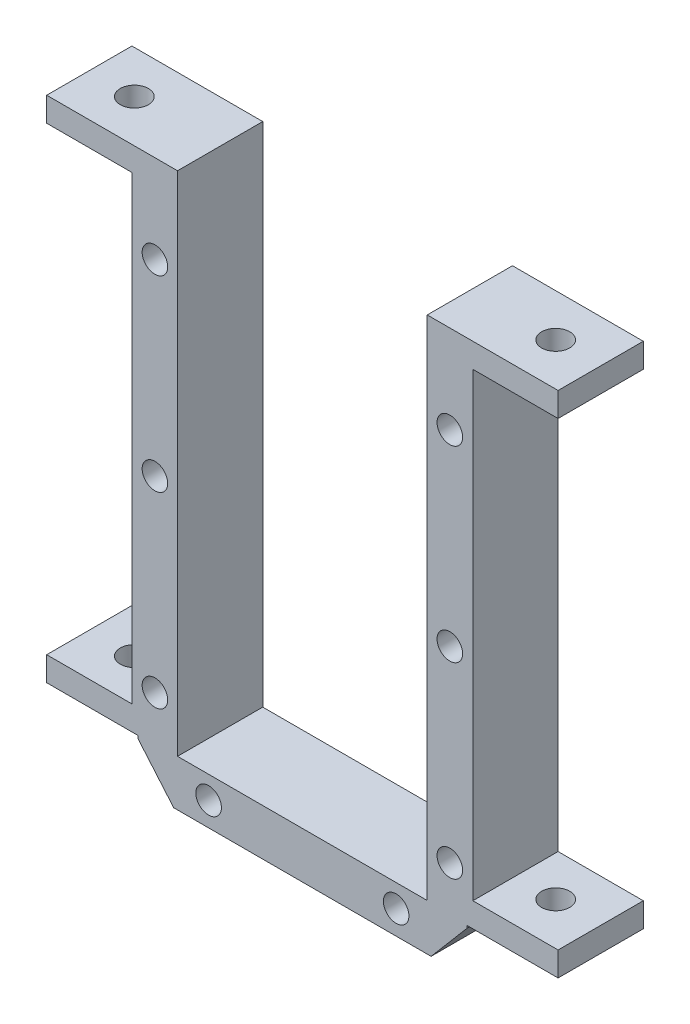
from build123d import *

# Parameters (mm, degrees)
SKETCH1_W               = 40
SKETCH1_H               = 65.1
BOSS_EXTRUDE1_DEPTH     = 10
CUT_EXTRUDE1_DEPTH      = 10
SKETCH4_W               = 29.3
SKETCH4_H               = 59.5
CUT_EXTRUDE2_DEPTH      = 10
SKETCH5_R               = 1.5
CUT_EXTRUDE3_DEPTH      = 10
SKETCH7_W               = 10
SKETCH7_H               = 3
BOSS_EXTRUDE2_DEPTH     = 10
SKETCH8_W               = 10
SKETCH8_H               = 3
BOSS_EXTRUDE3_DEPTH     = 10
SKETCH9_R               = 1.65
CUT_EXTRUDE4_DEPTH      = 61
SKETCH10_R              = 1.65
CUT_EXTRUDE5_DEPTH      = 61
ESQUISSE1_W             = 15.35
ESQUISSE1_H             = 0.15
ESQUISSE1_W_2           = 29.3
ENL_V_MAT_EXTRU_1_DEPTH = 11


with BuildPart() as part:
    # Sketch1 → Boss-Extrude1 (new body)
    with BuildSketch(Plane.XY):
        with Locations((-0.1, 0)):
            Rectangle(SKETCH1_W, SKETCH1_H)
    extrude(amount=BOSS_EXTRUDE1_DEPTH)

    # Sketch2 → Cut-Extrude1 (cut)
    with BuildSketch(Plane.XY.offset(10)):
        Polygon((15, -32.55), (19.335, -27.45), (19.9, -27.45), (19.9, -32.55), align=None)
        Polygon((-20.1, -27.45), (-20.1, -32.55), (-15.2, -32.55), (-19.535, -27.45), align=None)
    extrude(amount=-CUT_EXTRUDE1_DEPTH, mode=Mode.SUBTRACT)

    # Sketch4 → Cut-Extrude2 (cut)
    with BuildSketch(Plane.XY.offset(10)):
        with Locations((-0.1, 2.8)):
            Rectangle(SKETCH4_W, SKETCH4_H)
    extrude(amount=-CUT_EXTRUDE2_DEPTH, mode=Mode.SUBTRACT)

    # Sketch5 → Cut-Extrude3 (cut)
    with BuildSketch(Plane.XY.offset(10)):
        with Locations((-17.4, 22.05)):
            Circle(SKETCH5_R)
        with Locations((-17.4, 0.05)):
            Circle(SKETCH5_R)
        with Locations((-17.4, -21.95)):
            Circle(SKETCH5_R)
        with Locations((-11.1, -29.75)):
            Circle(SKETCH5_R)
        with Locations((10.9, -29.75)):
            Circle(SKETCH5_R)
        with Locations((17.2, -21.95)):
            Circle(SKETCH5_R)
        with Locations((17.2, 0.05)):
            Circle(SKETCH5_R)
        with Locations((17.2, 22.05)):
            Circle(SKETCH5_R)
    extrude(amount=-CUT_EXTRUDE3_DEPTH, mode=Mode.SUBTRACT)

    # Sketch7 → Boss-Extrude2 (add)
    with BuildSketch(Plane(origin=(19.9, 0, 0), x_dir=(0, 0, -1), z_dir=(1, 0, 0))):
        with Locations((-5, 31.05)):
            Rectangle(SKETCH7_W, SKETCH7_H)
        with Locations((-5, -25.95)):
            Rectangle(SKETCH7_W, SKETCH7_H)
    extrude(amount=BOSS_EXTRUDE2_DEPTH)

    # Sketch8 → Boss-Extrude3 (add)
    with BuildSketch(Plane.ZY.offset(20.1)):
        with Locations((5, 31.05)):
            Rectangle(SKETCH8_W, SKETCH8_H)
        with Locations((5, -25.95)):
            Rectangle(SKETCH8_W, SKETCH8_H)
    extrude(amount=BOSS_EXTRUDE3_DEPTH)

    # Sketch9 → Cut-Extrude4 (cut, through all)
    with BuildSketch(Plane(origin=(0, -27.45, 0), x_dir=(-1, 0, 0), z_dir=(0, -1, 0))):
        with Locations((24.8175, -5)):
            Circle(SKETCH9_R)
    extrude(amount=-CUT_EXTRUDE4_DEPTH, mode=Mode.SUBTRACT)

    # Sketch10 → Cut-Extrude5 (cut, through all)
    with BuildSketch(Plane(origin=(0, -27.45, 0), x_dir=(-1, 0, 0), z_dir=(0, -1, 0))):
        with Locations((-24.6175, -5)):
            Circle(SKETCH10_R)
    extrude(amount=-CUT_EXTRUDE5_DEPTH, mode=Mode.SUBTRACT)

    # Esquisse1 → Enlèv. mat.-Extru.1 (cut, through all)
    with BuildSketch(Plane.XY.offset(10)):
        Polygon((29.9, -27.45), (29.9, -27.3), (19.335, -27.3), (19.185, -27.3), (19.185, -27.905597112), (27.185, -27.905597112), (27.185, -27.45), align=None)
        with Locations((22.225, 32.475)):
            Rectangle(ESQUISSE1_W, ESQUISSE1_H)
        Polygon((-27.385, -27.905597112), (-27.385, -27.45), (-30.1, -27.45), (-30.1, -27.3), (-19.535, -27.3), (-19.385, -27.3), (-19.385, -27.905597112), align=None)
        with Locations((-22.425, 32.475)):
            Rectangle(ESQUISSE1_W, ESQUISSE1_H)
        with Locations((-0.1, -27.025)):
            Rectangle(ESQUISSE1_W_2, ESQUISSE1_H)
    extrude(amount=-ENL_V_MAT_EXTRU_1_DEPTH, mode=Mode.SUBTRACT)


solid = part.part
